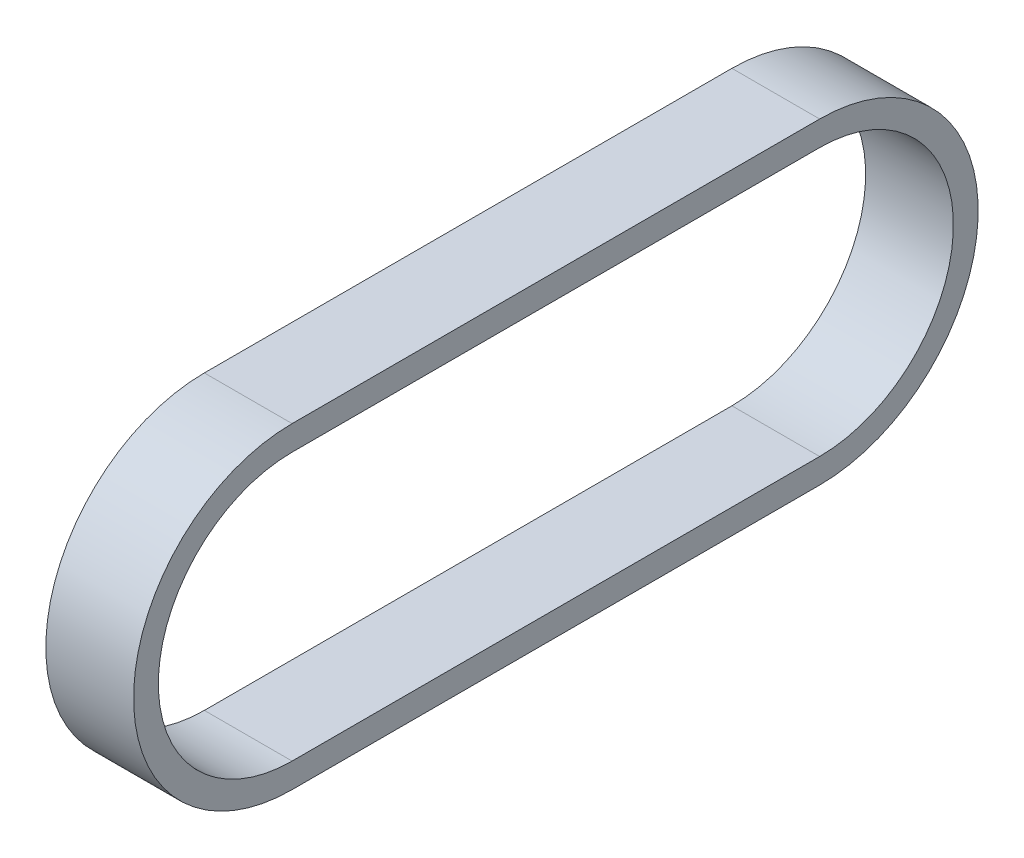
from build123d import *

# Parameters (mm, degrees)
EXTRUDE_THIN1_DEPTH = 9


with BuildPart() as part:
    # Sketch1 → Extrude-Thin1 (new body)
    with BuildSketch(Plane(origin=(0, 0, 0), x_dir=(0, 0, -1), z_dir=(1, 0, 0))):
        with BuildLine():
            Line((54.102, -16.256), (0, -16.256))
            ThreePointArc((0, -16.256), (-16.256, 0), (0, 16.256))
            Line((0, 16.256), (54.102, 16.256))
            ThreePointArc((54.102, 16.256), (70.358, 0), (54.102, -16.256))
        make_face()
        with BuildLine():
            Line((54.102, -13.716), (0, -13.716))
            ThreePointArc((0, -13.716), (-13.716, 0), (0, 13.716))
            Line((0, 13.716), (54.102, 13.716))
            ThreePointArc((54.102, 13.716), (67.818, 0), (54.102, -13.716))
        make_face(mode=Mode.SUBTRACT)
    extrude(amount=EXTRUDE_THIN1_DEPTH)


solid = part.part
